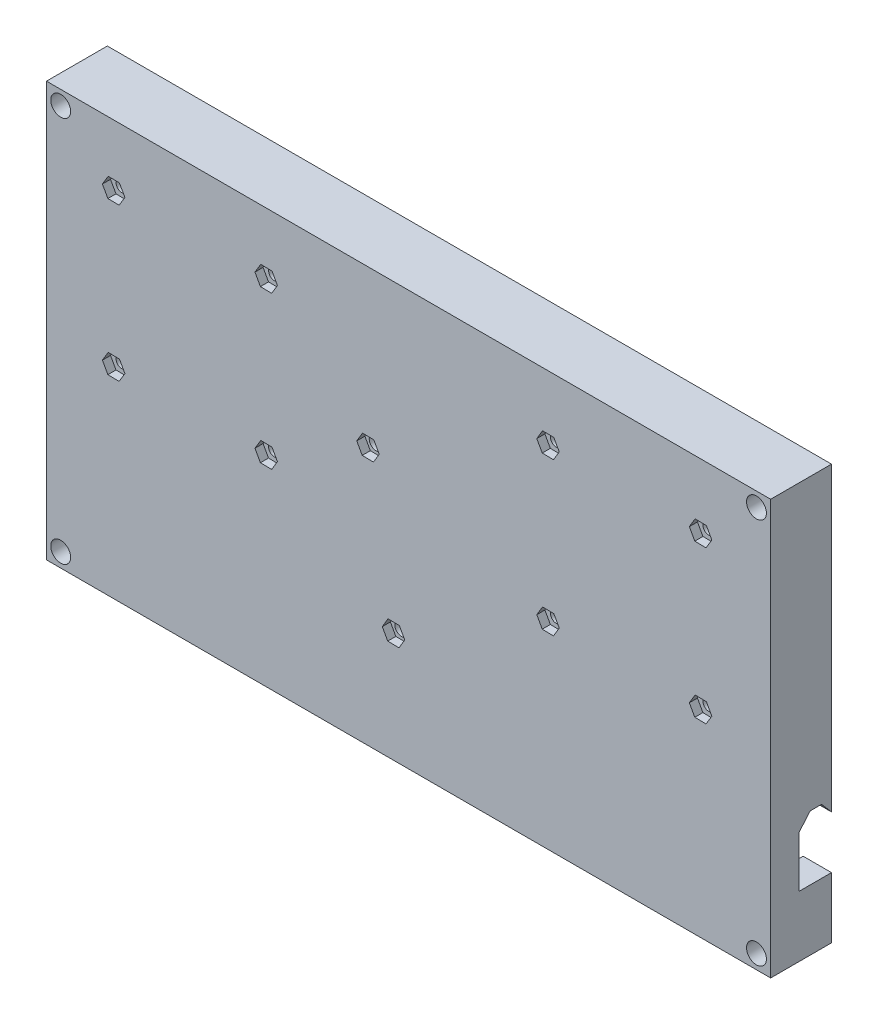
from build123d import *

# Parameters (mm, degrees)
SKETCH_1_W               = 164.5
SKETCH_1_H               = 88.2
EXTRUDE_1_DEPTH          = 4
SKETCH_2_W               = 178.5
SKETCH_2_H               = 102.2
SKETCH_2_R               = 2.45
SKETCH_2_W_2             = 164.5
SKETCH_2_H_2             = 88.2
EXTRUDE_3_DEPTH          = 15
EXTRUDE_5_DEPTH          = 5
CUT_EXTRUDE_3_DEPTH      = 104.43003674
CUT_EXTRUDE_3_DEPTH_BACK = 104.43003674
SKETCH_3_4_R             = 1.7
EXTRUDE_6_DEPTH          = 5
CUT_EXTRUDE_4_DEPTH      = 104.43003674
CUT_EXTRUDE_4_DEPTH_BACK = 104.43003674
SKETCH_4_3_R             = 1.4
CUT_EXTRUDE_5_DEPTH      = 186.995860169
CUT_EXTRUDE_5_DEPTH_BACK = 186.995860169
CUT_EXTRUDE_6_DEPTH      = 2


with BuildPart() as part:
    # 스케치1 → 보스-돌출1 (new body)
    with BuildSketch(Plane.XY):
        Rectangle(SKETCH_1_W, SKETCH_1_H)
    extrude(amount=EXTRUDE_1_DEPTH)

    # 스케치2 → 보스-돌출3 (add)
    with BuildSketch(Plane.XY.offset(4)):
        Rectangle(SKETCH_2_W, SKETCH_2_H)
        with Locations((-85.75, 47.6)):
            Circle(SKETCH_2_R, mode=Mode.SUBTRACT)
        with Locations((-85.75, -47.6)):
            Circle(SKETCH_2_R, mode=Mode.SUBTRACT)
        with Locations((85.75, 47.6)):
            Circle(SKETCH_2_R, mode=Mode.SUBTRACT)
        with Locations((85.75, -47.6)):
            Circle(SKETCH_2_R, mode=Mode.SUBTRACT)
        Rectangle(SKETCH_2_W_2, SKETCH_2_H_2, mode=Mode.SUBTRACT)
    extrude(amount=-EXTRUDE_3_DEPTH)

    # 스케치3 → 보스-돌출5 (add)
    with BuildSketch(Plane(origin=(0, 0, 0), x_dir=(-1, 0, 0), z_dir=(0, 0, -1))):
        Polygon((0, 29.6), (-21.7, 29.6), (-21.7, -29.7), (21.7, -29.7), (21.7, 29.6), (11, 29.6), (11, 27.1), (19.2, 27.1), (19.2, -27.2), (-19.2, -27.2), (-19.2, 27.1), (0, 27.1), align=None)
    extrude(amount=EXTRUDE_5_DEPTH)

    # 스케치3<4> → 컷-돌출3 (cut, two sides: drawn at the far end of the back side and taken through both)
    with BuildSketch(Plane(origin=(0, 0, 0), x_dir=(-1, 0, 0), z_dir=(0, 0, -1)).offset(-CUT_EXTRUDE_3_DEPTH_BACK)):
        with Locations((10, 12.5)):
            Circle(SKETCH_3_4_R)
        with Locations((3.71, -24)):
            Circle(SKETCH_3_4_R)
    extrude(amount=CUT_EXTRUDE_3_DEPTH + CUT_EXTRUDE_3_DEPTH_BACK, mode=Mode.SUBTRACT)

    # 스케치4 → 보스-돌출6 (add)
    with BuildSketch(Plane(origin=(0, 0, 0), x_dir=(-1, 0, 0), z_dir=(0, 0, -1))):
        Polygon((31.895357905, 14.983227458), (31.895357905, 39.183227458), (75.895357905, 39.183227458), (75.895357905, 14.983227458), (78.395357905, 14.983227458), (78.395357905, 41.683227458), (29.395357905, 41.683227458), (29.395357905, 14.983227458), align=None)
        Polygon((-75.174472702, 14.185349978), (-75.174472702, 38.385349978), (-31.174472702, 38.385349978), (-31.174472702, 14.185349978), (-28.674472702, 14.185349978), (-28.674472702, 40.885349978), (-77.674472702, 40.885349978), (-77.674472702, 14.185349978), align=None)
    extrude(amount=EXTRUDE_6_DEPTH)

    # 스케치4<3> → 컷-돌출4 (cut, two sides: drawn at the far end of the back side and taken through both)
    with BuildSketch(Plane(origin=(0, 0, 0), x_dir=(-1, 0, 0), z_dir=(0, 0, -1)).offset(-CUT_EXTRUDE_4_DEPTH_BACK)):
        with Locations((72.695357905, 35.983227458)):
            Circle(SKETCH_4_3_R)
        with Locations((72.695357905, -1.616772542)):
            Circle(SKETCH_4_3_R)
        with Locations((35.095357905, -1.616772542)):
            Circle(SKETCH_4_3_R)
        with Locations((35.095357905, 35.983227458)):
            Circle(SKETCH_4_3_R)
        with Locations((-34.374472702, 35.185349978)):
            Circle(SKETCH_4_3_R)
        with Locations((-34.374472702, -2.414650022)):
            Circle(SKETCH_4_3_R)
        with Locations((-71.974472702, -2.414650022)):
            Circle(SKETCH_4_3_R)
        with Locations((-71.974472702, 35.185349978)):
            Circle(SKETCH_4_3_R)
    extrude(amount=CUT_EXTRUDE_4_DEPTH + CUT_EXTRUDE_4_DEPTH_BACK, mode=Mode.SUBTRACT)

    # 스케치5 → 컷-돌출5 (cut, two sides: drawn at the far end of the back side and taken through both)
    with BuildSketch(Plane.ZY.offset(89.25).offset(-CUT_EXTRUDE_5_DEPTH_BACK)):
        Polygon((-8.55, -20.3), (-5.75, -20.3), (-3, -23.5), (-3, -36.1), (-11.3, -36.1), (-11.3, -23.5), align=None)
    extrude(amount=CUT_EXTRUDE_5_DEPTH + CUT_EXTRUDE_5_DEPTH_BACK, mode=Mode.SUBTRACT)

    # 스케치6 → 컷-돌출6 (cut)
    with BuildSketch(Plane.XY.offset(4)):
        Polygon((-37.866270853, 36.028409728), (-36.519943372, 33.606137589), (-33.749030425, 33.560955319), (-32.324444958, 35.938045189), (-33.670772438, 38.360317328), (-36.441685386, 38.405499597), align=None)
        Polygon((-71.349030425, 33.560955319), (-69.924444958, 35.938045189), (-71.270772438, 38.360317328), (-74.041685386, 38.405499597), (-75.466270853, 36.028409728), (-74.119943372, 33.606137589), align=None)
        Polygon((-33.670772438, 0.760317328), (-36.441685386, 0.805499597), (-37.866270853, -1.571590272), (-36.519943372, -3.993862411), (-33.749030425, -4.039044681), (-32.324444958, -1.661954811), align=None)
        Polygon((-71.349030425, -4.039044681), (-69.924444958, -1.661954811), (-71.270772438, 0.760317328), (-74.041685386, 0.805499597), (-75.466270853, -1.571590272), (-74.119943372, -3.993862411), align=None)
        Polygon((35.799058169, 37.562439847), (33.028145222, 37.607622117), (31.603559755, 35.230532247), (32.949887235, 32.808260108), (35.720800183, 32.763077839), (37.14538565, 35.140167708), align=None)
        Polygon((33.028145222, 0.007622117), (31.603559755, -2.369467753), (32.949887235, -4.791739892), (35.720800183, -4.836922161), (37.14538565, -2.459832292), (35.799058169, -0.037560153), align=None)
        Polygon((69.203559755, 35.230532247), (70.549887235, 32.808260108), (73.320800183, 32.763077839), (74.74538565, 35.140167708), (73.399058169, 37.562439847), (70.628145222, 37.607622117), align=None)
        Polygon((73.399058169, -0.037560153), (70.628145222, 0.007622117), (69.203559755, -2.369467753), (70.549887235, -4.791739892), (73.320800183, -4.836922161), (74.74538565, -2.459832292), align=None)
        Polygon((-11.346327481, 14.922272139), (-12.770912947, 12.54518227), (-11.424585467, 10.122910131), (-8.653672519, 10.077727861), (-7.229087053, 12.45481773), (-8.575414533, 14.877089869), align=None)
        Polygon((-5.056327481, -21.577727861), (-6.480912947, -23.95481773), (-5.134585467, -26.377089869), (-2.363672519, -26.422272139), (-0.939087053, -24.04518227), (-2.285414533, -21.622910131), align=None)
    extrude(amount=-CUT_EXTRUDE_6_DEPTH, mode=Mode.SUBTRACT)


solid = part.part
